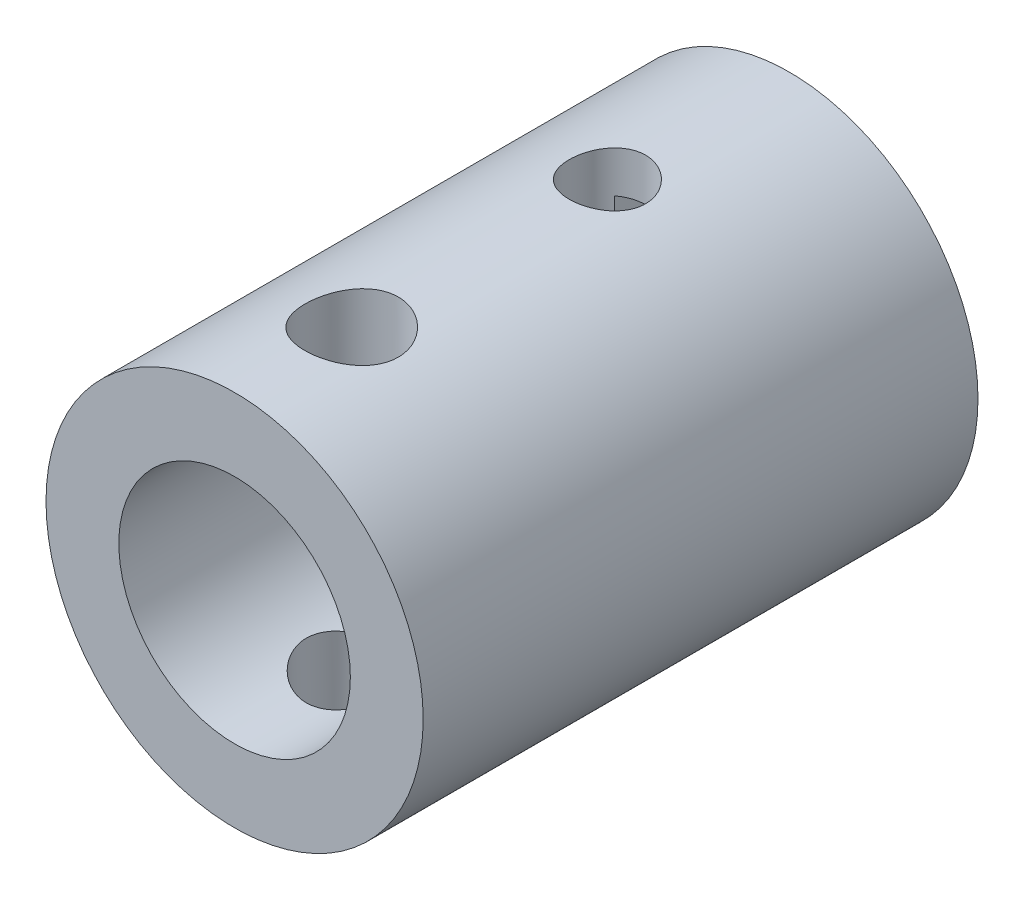
from build123d import *

# Parameters (mm, degrees)
SKETCH1_R                        = 25.9
BOSS_EXTRUDE1_DEPTH              = 76.2
SKETCH2_R                        = 15.9
CUT_EXTRUDE1_DEPTH               = 77.2
F_10_5_10_5_DIAMETER_HOLE1_D     = 10.5
F_10_5_10_5_DIAMETER_HOLE1_DEPTH = 20
F_10_5_10_5_DIAMETER_HOLE1_TIP   = 3.15451825
F_12_8_12_8_DIAMETER_HOLE1_D     = 12.8
F_12_8_12_8_DIAMETER_HOLE1_DEPTH = 300
F_12_8_12_8_DIAMETER_HOLE1_TIP   = 3.845507962
CUT_EXTRUDE2_DEPTH               = 35


with BuildPart() as part:
    # Sketch1 → Boss-Extrude1 (new body)
    with BuildSketch(Plane.XY):
        Circle(SKETCH1_R)
    extrude(amount=BOSS_EXTRUDE1_DEPTH)

    # Sketch2 → Cut-Extrude1 (cut, through all)
    with BuildSketch(Plane.XY.offset(76.2)):
        Circle(SKETCH2_R)
    extrude(amount=-CUT_EXTRUDE1_DEPTH, mode=Mode.SUBTRACT)

    # Ø10.5 (10.5) Diameter Hole1
    with Locations(Plane(origin=(0, 25.9, 25), x_dir=(0, 0, 1), z_dir=(0, 1, 0))):
        with Locations((0, 0)):
            Hole(F_10_5_10_5_DIAMETER_HOLE1_D / 2, depth=F_10_5_10_5_DIAMETER_HOLE1_DEPTH)
            with Locations((0, 0, -(F_10_5_10_5_DIAMETER_HOLE1_DEPTH + F_10_5_10_5_DIAMETER_HOLE1_TIP / 2))):  # 118° drill point
                Cone(0, F_10_5_10_5_DIAMETER_HOLE1_D / 2, F_10_5_10_5_DIAMETER_HOLE1_TIP, mode=Mode.SUBTRACT)

    # Ø12.8 (12.8) Diameter Hole1
    with Locations(Plane(origin=(-0.119429255, 25.899724644, 60), x_dir=(0.999989369, 0.004611168, 0), z_dir=(-0.004611168, 0.999989369, 0))):
        with Locations((0, 0)):
            Hole(F_12_8_12_8_DIAMETER_HOLE1_D / 2, depth=F_12_8_12_8_DIAMETER_HOLE1_DEPTH)
            with Locations((0, 0, -(F_12_8_12_8_DIAMETER_HOLE1_DEPTH + F_12_8_12_8_DIAMETER_HOLE1_TIP / 2))):  # 118° drill point
                Cone(0, F_12_8_12_8_DIAMETER_HOLE1_D / 2, F_12_8_12_8_DIAMETER_HOLE1_TIP, mode=Mode.SUBTRACT)

    # Sketch5 → Cut-Extrude2 (cut)
    with BuildSketch(Plane(origin=(0, 0, 0), x_dir=(-1, 0, 0), z_dir=(0, 0, -1))):
        with BuildLine():
            Line((-3.175, 20), (-3.175, 15.579774549))
            ThreePointArc((-3.175, 15.579774549), (0, 15.9), (3.175, 15.579774549))
            Line((3.175, 15.579774549), (3.175, 20))
            Line((3.175, 20), (-3.175, 20))
        make_face()
    extrude(amount=-CUT_EXTRUDE2_DEPTH, mode=Mode.SUBTRACT)


solid = part.part
